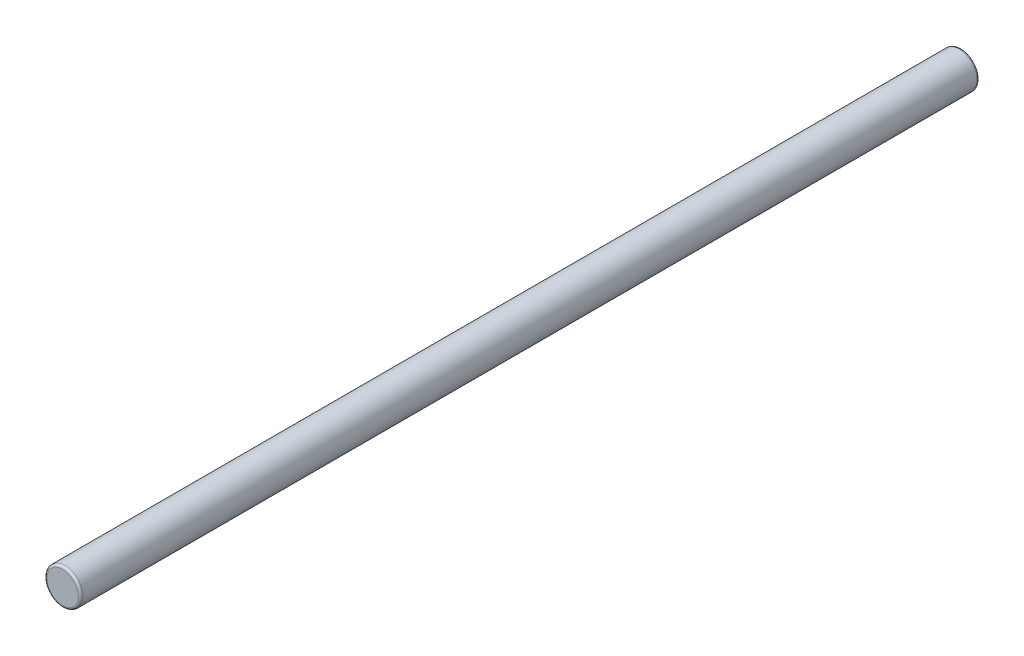
from build123d import *

# Parameters (mm, degrees)
SKETCH1_R           = 4
BOSS_EXTRUDE1_DEPTH = 200
FILLET1_R           = 0.5


with BuildPart() as part:
    # Sketch1 → Boss-Extrude1 (new body)
    with BuildSketch(Plane.XY):
        Circle(SKETCH1_R)
    extrude(amount=BOSS_EXTRUDE1_DEPTH)

    # Fillet1
    fillet1_edges = [part.edges().sort_by_distance(p)[0] for p in [
        (-4, 0, 0),
        (-4, 0, 200),
    ]]
    fillet(fillet1_edges, radius=FILLET1_R)


solid = part.part
